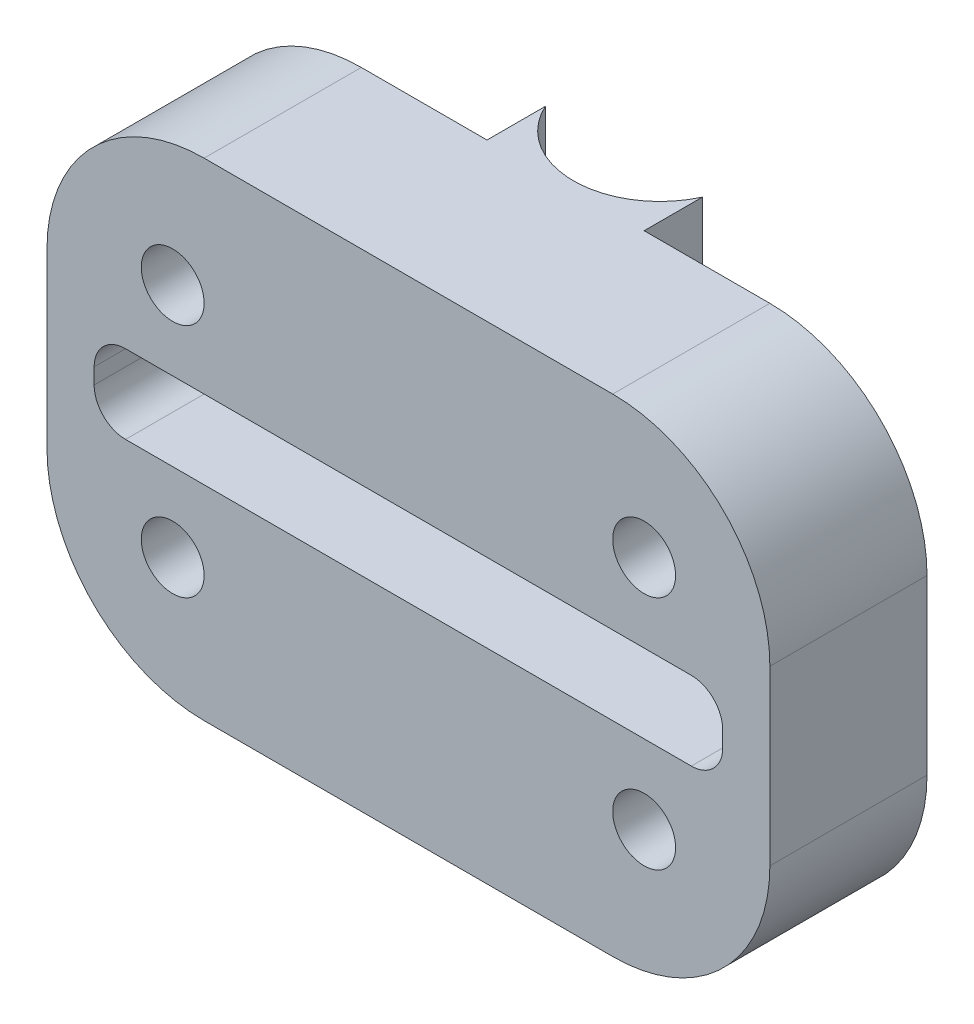
from build123d import *

# Parameters (mm, degrees)
SKETCH1_W               = 46
SKETCH1_H               = 31
SKETCH1_R               = 2
BOSS_EXTRUDE1_DEPTH     = 10
FILLET1_R               = 10
BOSS_EXTRUDE2_START     = 15.5
BOSS_EXTRUDE2_DEPTH     = 10
BOSS_EXTRUDE3_START     = -15.5
BOSS_EXTRUDE3_DEPTH     = 10
SKETCH4_W               = 40
SKETCH4_H               = 5
CUT_EXTRUDE1_DEPTH      = 30.483045976
CUT_EXTRUDE1_DEPTH_BACK = 30.483045976
FILLET2_R               = 2


with BuildPart() as part:
    # Sketch1 → Boss-Extrude1 (new body)
    with BuildSketch(Plane.XY):
        Rectangle(SKETCH1_W, SKETCH1_H)
        with Locations((-15, 7.5)):
            Circle(SKETCH1_R, mode=Mode.SUBTRACT)
        with Locations((15, 7.5)):
            Circle(SKETCH1_R, mode=Mode.SUBTRACT)
        with Locations((15, -7.5)):
            Circle(SKETCH1_R, mode=Mode.SUBTRACT)
        with Locations((-15, -7.5)):
            Circle(SKETCH1_R, mode=Mode.SUBTRACT)
    extrude(amount=BOSS_EXTRUDE1_DEPTH)

    # Fillet1
    fillet1_edges = [part.edges().sort_by_distance(p)[0] for p in [
        (23, -15.5, 5),
        (-23, -15.5, 5),
        (-23, 15.5, 5),
        (23, 15.5, 5),
    ]]
    fillet(fillet1_edges, radius=FILLET1_R)

    # Sketch3 → Boss-Extrude2 (add)
    with BuildSketch(Plane(origin=(0, 0, 0), x_dir=(1, 0, 0), z_dir=(0, 1, 0)).offset(BOSS_EXTRUDE2_START)):
        with BuildLine():
            Line((-5, 3.708712153), (-5, 0))
            Line((-5, 0), (5, 0))
            Line((5, 0), (5, 3.708712153))
            ThreePointArc((5, 3.708712153), (0, 0.5), (-5, 3.708712153))
        make_face()
    extrude(amount=-BOSS_EXTRUDE2_DEPTH)

    # Sketch3_3 → Boss-Extrude3 (add)
    with BuildSketch(Plane(origin=(0, 0, 0), x_dir=(1, 0, 0), z_dir=(0, 1, 0)).offset(BOSS_EXTRUDE3_START)):
        with BuildLine():
            Line((-5, 3.708712153), (-5, 0))
            Line((-5, 0), (5, 0))
            Line((5, 0), (5, 3.708712153))
            ThreePointArc((5, 3.708712153), (0, 0.5), (-5, 3.708712153))
        make_face()
    extrude(amount=BOSS_EXTRUDE3_DEPTH)

    # Sketch4 → Cut-Extrude1 (cut, two sides)
    with BuildSketch(Plane(origin=(0, 0, 0), x_dir=(-1, 0, 0), z_dir=(0, 0, -1))) as cut_extrude1_sk:
        Rectangle(SKETCH4_W, SKETCH4_H)
    extrude(amount=CUT_EXTRUDE1_DEPTH, mode=Mode.SUBTRACT)
    extrude(cut_extrude1_sk.sketch, amount=-CUT_EXTRUDE1_DEPTH_BACK, mode=Mode.SUBTRACT)

    # Fillet2
    fillet2_edges = [part.edges().sort_by_distance(p)[0] for p in [
        (-20, 2.5, 5),
        (-20, -2.5, 5),
        (20, -2.5, 5),
        (20, 2.5, 5),
    ]]
    fillet(fillet2_edges, radius=FILLET2_R)


solid = part.part
